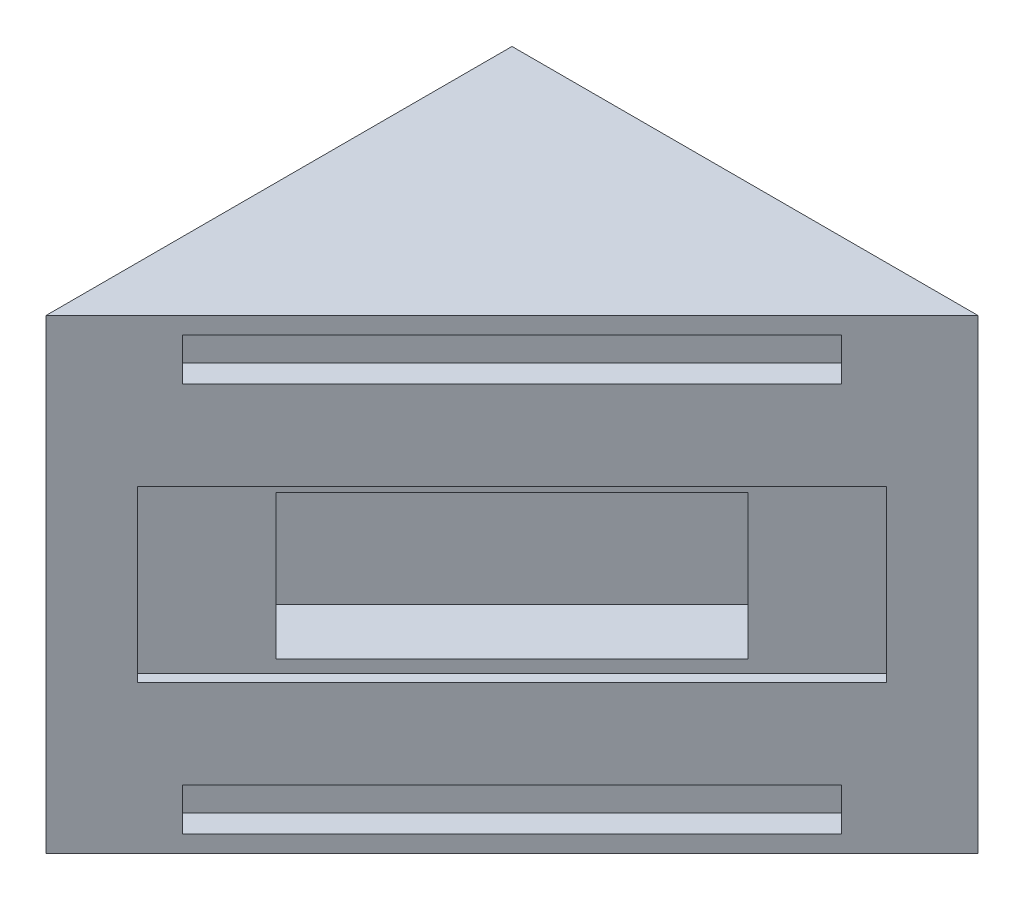
from build123d import *

# Parameters (mm, degrees)
SKETCH1_W           = 69.85
SKETCH1_H           = 69.85
BOSS_EXTRUDE1_DEPTH = 69.85
CUT_EXTRUDE2_DEPTH  = 100
SKETCH3_W           = 69.85
SKETCH3_H           = 6.35
CUT_EXTRUDE4_DEPTH  = 3.81
SKETCH4_W           = 79.375
SKETCH4_H           = 25.4
CUT_EXTRUDE5_DEPTH  = 1.6
SKETCH5_W           = 50
SKETCH5_H           = 21.59
CUT_EXTRUDE6_DEPTH  = 10


with BuildPart() as part:
    # Sketch1 → Boss-Extrude1 (new body)
    with BuildSketch(Plane(origin=(0, 0, 0), x_dir=(1, 0, 0), z_dir=(0, 1, 0))):
        with Locations((34.925, 34.925)):
            Rectangle(SKETCH1_W, SKETCH1_H)
    extrude(amount=BOSS_EXTRUDE1_DEPTH)

    # Sketch2 → Cut-Extrude2 (cut)
    with BuildSketch(Plane(origin=(0, 0, 0), x_dir=(0.707106781, 0, -0.707106781), z_dir=(0.707106781, 0, 0.707106781))):
        Polygon((98.782817332, 69.85), (98.782817332, 0), (49.391408666, 0), (0, 0), (0, 69.85), (49.391408666, 69.85), align=None)
    extrude(amount=CUT_EXTRUDE2_DEPTH, mode=Mode.SUBTRACT)

    # Sketch3 → Cut-Extrude4 (cut)
    with BuildSketch(Plane(origin=(0, 0, 0), x_dir=(0.707106781, 0, -0.707106781), z_dir=(0.707106781, 0, 0.707106781))):
        with Locations((49.391408666, 5.715)):
            Rectangle(SKETCH3_W, SKETCH3_H)
        with Locations((49.391408666, 64.135)):
            Rectangle(SKETCH3_W, SKETCH3_H)
    extrude(amount=-CUT_EXTRUDE4_DEPTH, mode=Mode.SUBTRACT)

    # Sketch4 → Cut-Extrude5 (cut)
    with BuildSketch(Plane(origin=(0, 0, 0), x_dir=(0.707106781, 0, -0.707106781), z_dir=(0.707106781, 0, 0.707106781))):
        with Locations((49.391408666, 34.925)):
            Rectangle(SKETCH4_W, SKETCH4_H)
    extrude(amount=-CUT_EXTRUDE5_DEPTH, mode=Mode.SUBTRACT)

    # Sketch5 → Cut-Extrude6 (cut)
    with BuildSketch(Plane(origin=(-1.13137085, 0, -1.13137085), x_dir=(0.707106781, 0, -0.707106781), z_dir=(0.707106781, 0, 0.707106781))):
        with Locations((49.391408666, 34.925)):
            Rectangle(SKETCH5_W, SKETCH5_H)
    extrude(amount=-CUT_EXTRUDE6_DEPTH, mode=Mode.SUBTRACT)


solid = part.part
